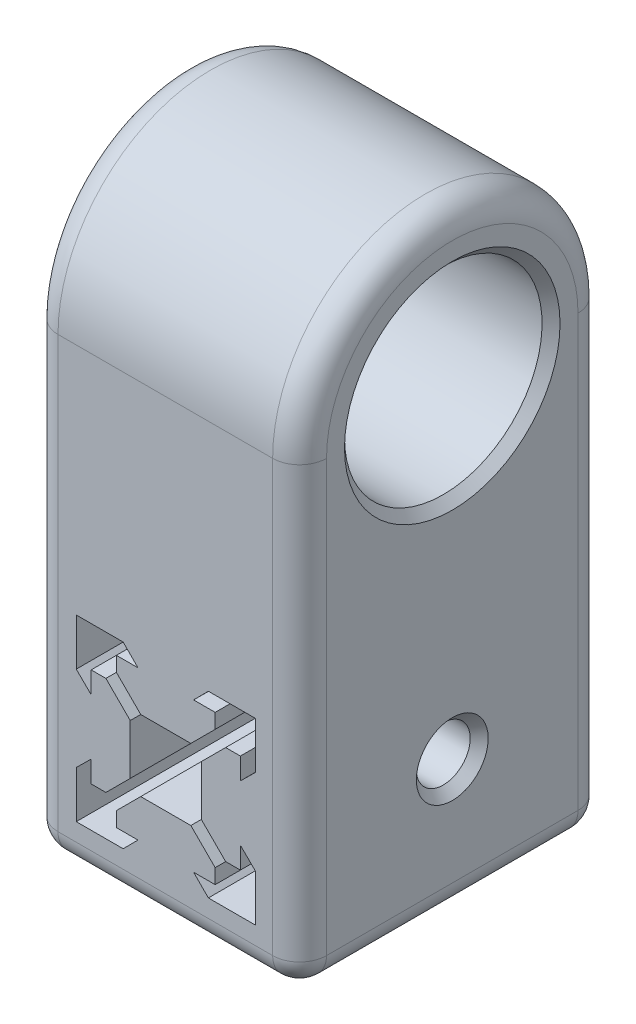
from build123d import *

# Parameters (mm, degrees)
BOSS_EXTRUDE1_DEPTH = 34
SKETCH5_R           = 11
BOSS_EXTRUDE3_DEPTH = 29.899298
SKETCH3_R           = 3
CUT_EXTRUDE1_DEPTH  = 30.899298428
FILLET1_R           = 3
CHAMFER1_SIZE       = 1


with BuildPart() as part:
    # Sketch1 → Boss-Extrude1 (new body)
    with BuildSketch(Plane.XY):
        Polygon((0, 15), (14.899298428, 15), (14.899298428, -14.949649214), (-15, -14.949649214), (-15, 15), align=None)
        Polygon((-9.966432809, 9.966432809), (-4.741432809, 9.966432809), (-3.1, 8.307461143), (-5.5, 8.307461143), (-5.5, 6.667461143), (-2.79, 3.957461143), (2.79, 3.957461143), (5.5, 6.667461143), (5.5, 8.307461143), (3.1, 8.307461143), (4.741432809, 9.966432809), (9.966432809, 9.966432809), (9.966432809, 4.741432809), (8.307461143, 3.1), (8.307461143, 5.5), (6.667461143, 5.5), (3.957461143, 2.79), (3.957461143, -2.79), (6.667461143, -5.5), (8.307461143, -5.5), (8.307461143, -3.1), (9.966432809, -4.741432809), (9.966432809, -9.966432809), (4.741432809, -9.966432809), (3.1, -8.307461143), (5.5, -8.307461143), (5.5, -6.667461143), (2.79, -3.957461143), (-2.79, -3.957461143), (-5.5, -6.667461143), (-5.5, -8.307461143), (-3.1, -8.307461143), (-4.741432809, -9.966432809), (-9.966432809, -9.966432809), (-9.966432809, -4.741432809), (-8.307461143, -3.1), (-8.307461143, -5.5), (-6.667461143, -5.5), (-3.957461143, -2.79), (-3.957461143, 2.79), (-6.667461143, 5.5), (-8.307461143, 5.5), (-8.307461143, 3.1), (-9.966432809, 4.741432809), align=None, mode=Mode.SUBTRACT)
    extrude(amount=BOSS_EXTRUDE1_DEPTH)

    # Sketch5 → Boss-Extrude3 (add, through all)
    with BuildSketch(Plane.ZY.offset(15)):
        with BuildLine():
            Line((0, 36), (0, 15))
            Line((0, 15), (0, 12.8756905))
            Line((0, 12.8756905), (34, 12.8756905))
            Line((34, 12.8756905), (34, 36))
            ThreePointArc((34, 36), (17, 53), (0, 36))
        make_face()
        with Locations((17, 36)):
            Circle(SKETCH5_R, mode=Mode.SUBTRACT)
    extrude(amount=-BOSS_EXTRUDE3_DEPTH)

    # Sketch3 → Cut-Extrude1 (cut, through all)
    with BuildSketch(Plane.ZY.offset(15)):
        with Locations((17, 0)):
            Circle(SKETCH3_R)
    extrude(amount=-CUT_EXTRUDE1_DEPTH, mode=Mode.SUBTRACT)

    # Fillet1
    fillet1_edges = [part.edges().sort_by_distance(p)[0] for p in [
        (-0.050350786, -14.949649214, 34),
        (14.899298428, 0.025175393, 34),
        (-15, 53, 17),
        (14.899298, 53, 17),
        (14.899298428, 0.025175393, 0),
        (-0.050350786, -14.949649214, 0),
        (-15, 10.525175393, 0),
        (-15, 10.525175393, 34),
        (14.899298428, -14.949649214, 17),
        (-15, -14.949649214, 17),
    ]]
    fillet(fillet1_edges, radius=FILLET1_R)

    # Chamfer1
    chamfer1_edges = [part.edges().sort_by_distance(p)[0] for p in [
        (14.899298, 36, 6),
        (-15, 36, 6),
        (14.899298428, 0, 14),
        (-15, 0, 14),
    ]]
    chamfer(chamfer1_edges, length=CHAMFER1_SIZE)


solid = part.part
